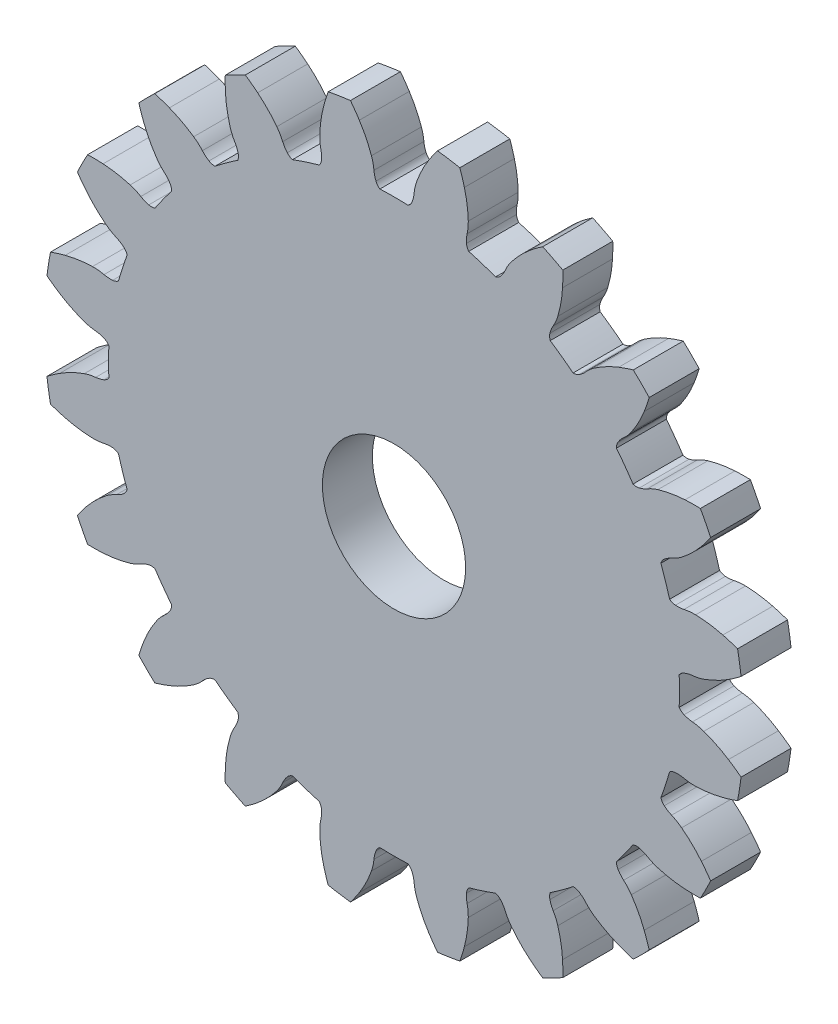
from build123d import *

# Parameters (mm, degrees)
SKETCH4_R           = 21
SKETCH4_R_2         = 4.3
BOSS_EXTRUDE1_DEPTH = 3
CUT_EXTRUDE1_DEPTH  = 4
CIRPATTERN2_COUNT   = 20


with BuildPart() as part:
    # Sketch4 → Boss-Extrude1 (new body)
    with BuildSketch(Plane.XY):
        with Locations((19.098593171, 0)):
            Circle(SKETCH4_R)
        with Locations((19.098593171, 0)):
            Circle(SKETCH4_R_2, mode=Mode.SUBTRACT)
    extrude(amount=BOSS_EXTRUDE1_DEPTH)

    # Sketch6 → Cut-Extrude1 (cut, through all)
    with BuildSketch(Plane.XY):
        with BuildLine():
            ThreePointArc((-0.980259778, -2.082031707), (-1.365175016, -2.341050989), (-1.738778243, -2.616135262))
            ThreePointArc((-1.738778243, -2.616135262), (-1.902364216, 0), (-1.738778243, 2.616135262))
            ThreePointArc((-1.738778243, 2.616135262), (-1.365175016, 2.341050989), (-0.980259778, 2.082031707))
            ThreePointArc((-0.980259778, 2.082031707), (-0.259894701, 1.675737519), (0.502403682, 1.354954122))
            ThreePointArc((0.502403682, 1.354954122), (0.838942189, 1.258881016), (1.184846586, 1.205604781))
            ThreePointArc((1.184846586, 1.205604781), (1.440491711, 1.162965754), (1.686881685, 1.082563659))
            ThreePointArc((1.686881685, 1.082563659), (1.849595825, 0.986093339), (1.97802282, 0.84720878))
            ThreePointArc((1.97802282, 0.84720878), (1.960969098, 0), (1.97802282, -0.84720878))
            ThreePointArc((1.97802282, -0.84720878), (1.849595825, -0.986093339), (1.686881685, -1.082563659))
            ThreePointArc((1.686881685, -1.082563659), (1.440491711, -1.162965754), (1.184846586, -1.205604781))
            ThreePointArc((1.184846586, -1.205604781), (0.838942189, -1.258881016), (0.502403682, -1.354954122))
            ThreePointArc((0.502403682, -1.354954122), (-0.259894701, -1.675737519), (-0.980259778, -2.082031707))
        make_face()
    cut_extrude1 = extrude(amount=CUT_EXTRUDE1_DEPTH, mode=Mode.SUBTRACT)

    # CirPattern2: Cut-Extrude1 ×20 about axis
    cirpattern2_axis = Axis((19.098593171, 0, 0), (0, 0, 1))
    for i in range(1, CIRPATTERN2_COUNT):
        add(cut_extrude1.rotate(cirpattern2_axis, i * 360 / CIRPATTERN2_COUNT), mode=Mode.SUBTRACT)


solid = part.part
